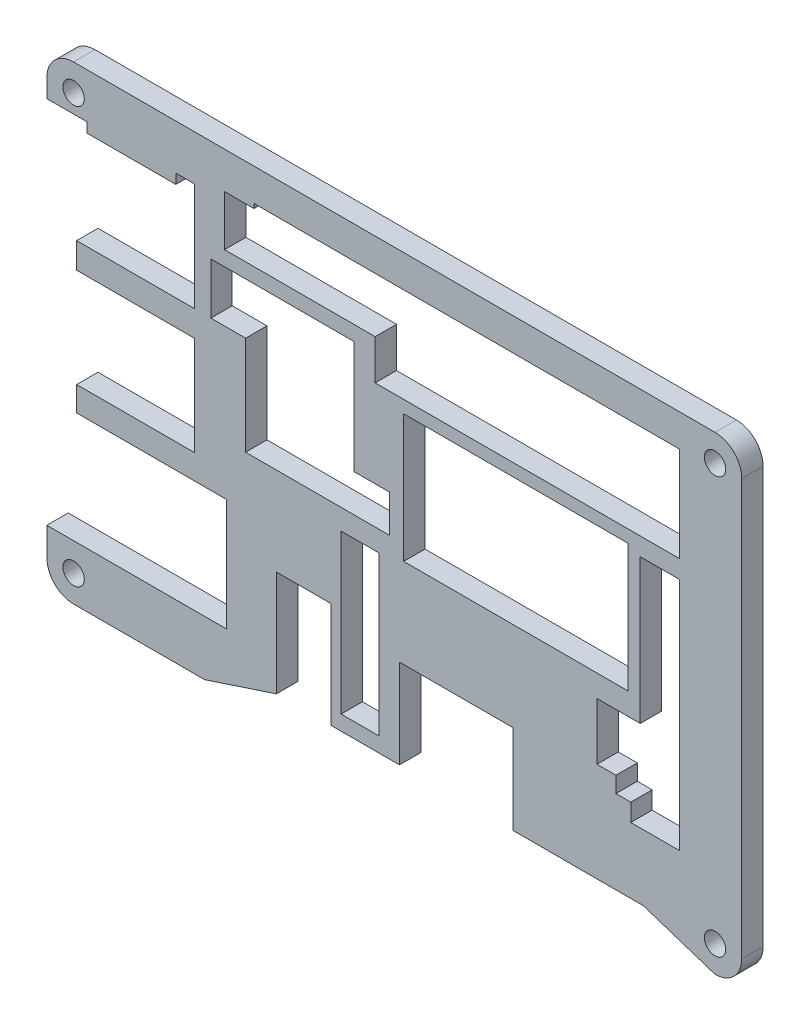
from build123d import *

# Parameters (mm, degrees)
SKETCH2_W           = 5.4034
SKETCH2_H           = 22.6066
SKETCH2_W_2         = 31.9679
SKETCH2_H_2         = 18.2371
BOSS_EXTRUDE1_DEPTH = 3.048
SKETCH3_R           = 1.338245378
CUT_EXTRUDE1_DEPTH  = 4.048
SKETCH4_R           = 1.524
CUT_EXTRUDE2_DEPTH  = 4.048
SKETCH5_W           = 13.7159
SKETCH5_H           = 5.7149
SKETCH5_W_2         = 4.1917
SKETCH5_H_2         = 7.175
CUT_EXTRUDE3_DEPTH  = 4.048
SKETCH7_W           = 12.7
SKETCH7_H           = 1.397
BOSS_EXTRUDE3_DEPTH = 3.048


with BuildPart() as part:
    # Sketch2 → Boss-Extrude1 (new body)
    with BuildSketch(Plane(origin=(0, 0, 8.171752382), x_dir=(-1, 0, 0), z_dir=(0, 0, -1))):
        with BuildLine():
            Line((-23.844892625, -33.084405696), (-34.084892625, -36.451005696))
            ThreePointArc((-34.084892625, -36.451005696), (-36.778969461, -35.335082532), (-37.894892625, -32.641005696))
            Line((-37.894892625, -32.641005696), (-37.894892625, 26.697694304))
            ThreePointArc((-37.894892625, 26.697694304), (-36.778969461, 29.391771141), (-34.084892625, 30.507694304))
            Line((-34.084892625, 30.507694304), (57.404932375, 30.507694304))
            ThreePointArc((57.404932375, 30.507694304), (60.103884597, 29.386886916), (61.214907375, 26.683892153))
            Line((61.214907375, 26.683892153), (61.214907375, 24.068294304))
            Line((61.214907375, 24.068294304), (40.134807375, 24.068294304))
            Line((40.134807375, 24.068294304), (40.134807375, 8.658194304))
            Line((40.134807375, 8.658194304), (56.975007375, 8.658194304))
            Line((56.975007375, 8.658194304), (56.975007375, 4.997894304))
            Line((56.975007375, 4.997894304), (40.134807375, 4.997894304))
            Line((40.134807375, 4.997894304), (40.134807375, -9.121805696))
            Line((40.134807375, -9.121805696), (56.975007375, -9.121805696))
            Line((56.975007375, -9.121805696), (56.975007375, -12.628005696))
            Line((56.975007375, -12.628005696), (35.575007375, -12.628005696))
            Line((35.575007375, -12.628005696), (35.575007375, -28.627805696))
            Line((35.575007375, -28.627805696), (61.214907375, -28.627805696))
            Line((61.214907375, -28.627805696), (61.214907375, -32.613401529))
            ThreePointArc((61.214907375, -32.613401529), (60.108826144, -35.325305244), (57.405007375, -36.451005696))
            Line((57.405007375, -36.451005696), (38.714307375, -36.451005696))
            Line((38.714307375, -36.451005696), (28.474307375, -33.084405696))
            Line((28.474307375, -33.084405696), (28.474307375, -18.034905696))
            Line((28.474307375, -18.034905696), (20.658107375, -18.034905696))
            Line((20.658107375, -18.034905696), (20.658107375, -33.084405696))
            Line((20.658107375, -33.084405696), (10.926407375, -33.084405696))
            Line((10.926407375, -33.084405696), (10.926407375, -20.384405696))
            Line((10.926407375, -20.384405696), (-5.302892625, -20.384405696))
            Line((-5.302892625, -20.384405696), (-5.302892625, -33.084405696))
            Line((-5.302892625, -33.084405696), (-23.844892625, -33.084405696))
        make_face()
        with Locations((16.546707375, -19.663505696)):
            Rectangle(SKETCH2_W, SKETCH2_H, mode=Mode.SUBTRACT)
        Polygon((-29.004892625, -23.698905696), (-22.066892625, -23.698905696), (-22.066892625, -21.185805696), (-19.950892625, -21.185805696), (-19.950892625, -18.920605696), (-17.244692625, -18.920605696), (-17.244692625, -10.792605696), (-23.416892625, -10.792605696), (-23.416892625, 9.801194304), (-29.004892625, 9.801194304), align=None, mode=Mode.SUBTRACT)
        with Locations((-5.654942625, 1.475544304)):
            Rectangle(SKETCH2_W_2, SKETCH2_H_2, mode=Mode.SUBTRACT)
        Polygon((12.361007375, -0.097605696), (17.441007375, -0.097605696), (17.441007375, 15.972394304), (37.825007375, 15.972394304), (37.825007375, 8.658194304), (32.872007375, 8.658194304), (32.872007375, -5.431505696), (12.361007375, -5.431505696), align=None, mode=Mode.SUBTRACT)
        Polygon((0.677107375, 12.372094304), (-29.004794688, 12.372094304), (-29.004892625, 25.896994304), (31.688307375, 25.896994304), (31.688307375, 18.086994304), (0.677107375, 18.086994304), align=None, mode=Mode.SUBTRACT)
    extrude(amount=BOSS_EXTRUDE1_DEPTH)

    # Sketch3 → Cut-Extrude1 (cut, through all)
    with BuildSketch(Plane(origin=(0, 0, 5.123752382), x_dir=(-1, 0, 0), z_dir=(0, 0, -1))):
        with Locations((57.405007375, -32.641005696)):
            Circle(SKETCH3_R)
        with Locations((-34.084892625, -32.641005696)):
            Circle(SKETCH3_R)
        with Locations((-34.084892625, 26.697694304)):
            Circle(SKETCH3_R)
        with Locations((57.404932375, 26.697694304)):
            Circle(SKETCH3_R)
    extrude(amount=-CUT_EXTRUDE1_DEPTH, mode=Mode.SUBTRACT)

    # Sketch4 → Cut-Extrude2 (cut, through all)
    with BuildSketch(Plane(origin=(0, 0, 5.123752382), x_dir=(-1, 0, 0), z_dir=(0, 0, -1))):
        with Locations((-34.084892625, 26.697694304)):
            Circle(SKETCH4_R)
        with Locations((-34.084892625, -32.641005696)):
            Circle(SKETCH4_R)
        with Locations((57.405007375, -32.641005696)):
            Circle(SKETCH4_R)
        with Locations((57.404932375, 26.697694304)):
            Circle(SKETCH4_R)
    extrude(amount=-CUT_EXTRUDE2_DEPTH, mode=Mode.SUBTRACT)

    # Sketch5 → Cut-Extrude3 (cut, through all)
    with BuildSketch(Plane(origin=(0, 0, 5.123752382), x_dir=(-1, 0, 0), z_dir=(0, 0, -1))):
        with Locations((7.535057375, 15.229544304)):
            Rectangle(SKETCH5_W, SKETCH5_H)
        with Locations((33.784157375, 21.674494304)):
            Rectangle(SKETCH5_W_2, SKETCH5_H_2)
    extrude(amount=-CUT_EXTRUDE3_DEPTH, mode=Mode.SUBTRACT)

    # Sketch7 → Boss-Extrude3 (add)
    with BuildSketch(Plane(origin=(0, 0, 5.123752382), x_dir=(-1, 0, 0), z_dir=(0, 0, -1))):
        with Locations((49.175307375, 23.369794304)):
            Rectangle(SKETCH7_W, SKETCH7_H)
    extrude(amount=-BOSS_EXTRUDE3_DEPTH)


solid = part.part
